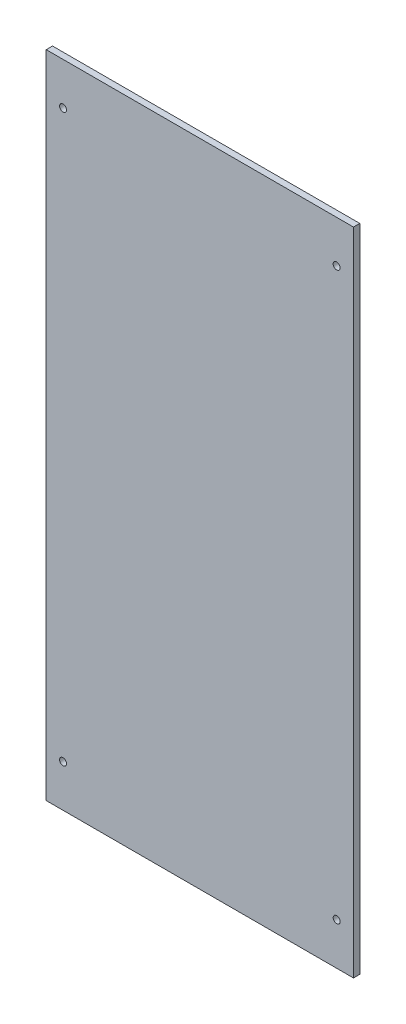
from build123d import *

# Parameters (mm, degrees)
ESQUISSE1_W             = 146
ESQUISSE1_H             = 309
BOSS_EXTRU_1_DEPTH      = 3
ESQUISSE2_R             = 1.65
ENL_V_MAT_EXTRU_1_DEPTH = 4


with BuildPart() as part:
    # Esquisse1 → Boss.-Extru.1 (new body)
    with BuildSketch(Plane.XY):
        with Locations((73, 154.5)):
            Rectangle(ESQUISSE1_W, ESQUISSE1_H)
    extrude(amount=BOSS_EXTRU_1_DEPTH)

    # Esquisse2 → Enlèv. mat.-Extru.1 (cut, through all)
    with BuildSketch(Plane.XY.offset(3)):
        with Locations((8, 289)):
            Circle(ESQUISSE2_R)
        with Locations((138, 289)):
            Circle(ESQUISSE2_R)
        with Locations((138, 20)):
            Circle(ESQUISSE2_R)
        with Locations((8, 20)):
            Circle(ESQUISSE2_R)
    extrude(amount=-ENL_V_MAT_EXTRU_1_DEPTH, mode=Mode.SUBTRACT)


solid = part.part
